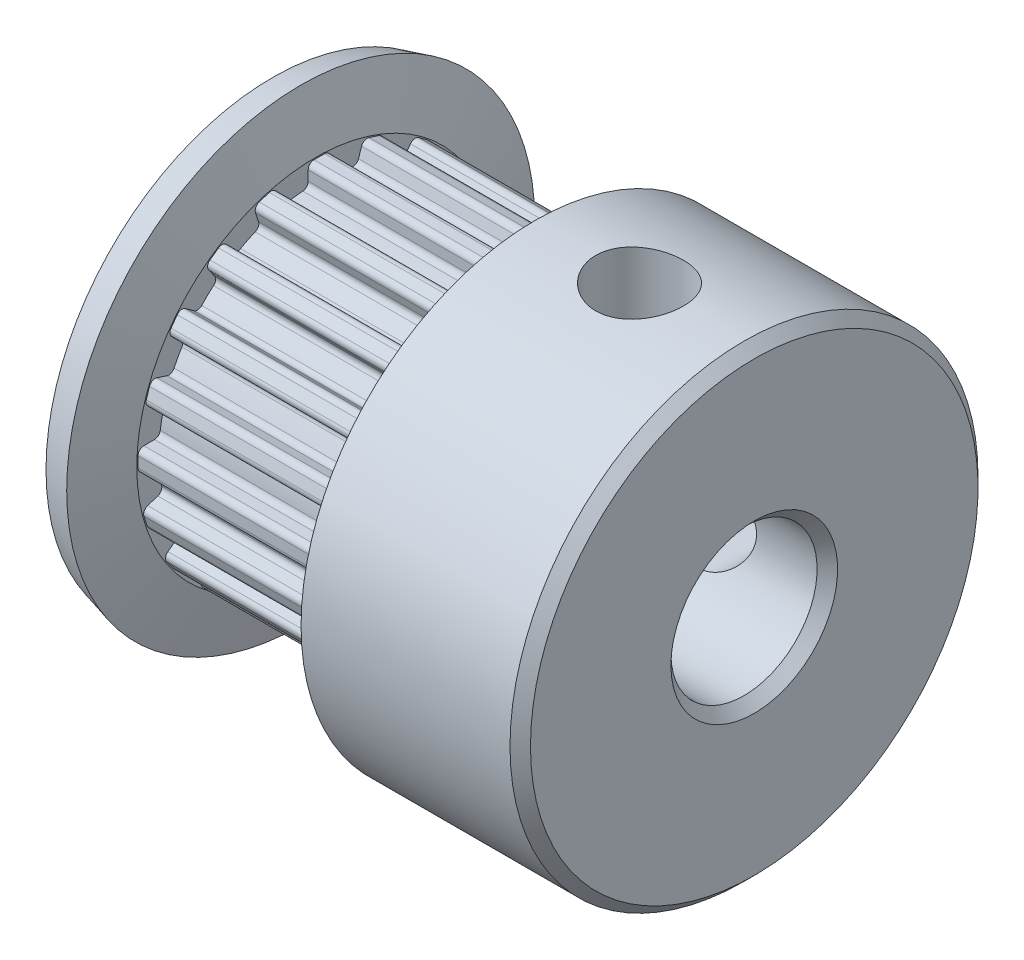
from build123d import *

# Parameters (mm, degrees)
SKETCH2_W                = 0.76
SKETCH2_H                = 0.76
BOSS_EXTRUDE1_DEPTH      = 7
FILLET1_R                = 0.2
CIRPATTERN2_COUNT        = 20
FILLET1_OF_CIRPATTERN2_R = 0.2
CUT_EXTRUDE2_START       = -3
SKETCH3_R                = 1.5
CUT_EXTRUDE2_DEPTH       = 12
CIRPATTERN3_COUNT        = 2
CIRPATTERN3_ANGLE        = 90


with BuildPart() as part:
    # Sketch1 → Revolve2 (revolve)
    with BuildSketch(Plane.XY):
        Polygon((8.222365613, 5.5), (1.078789587, 5.5), (0.572365613, 3.61), (0.572365613, 2.85), (-6.427634387, 2.85), (-6.427634387, 3.61), (-6.934058361, 5.5), (-7.899984187, 5.241180955), (-7.427634387, 3.478347502), (-7.427634387, 2.85), (-7.427634387, 0.35), (-7.077634387, 0), (8.222365613, 0), (8.572365613, 0.35), (8.572365613, 5.15), align=None)
    revolve(axis=Axis((-7.427634387, -2.5, 0), (1, 0, 0)))

    # Sketch2 → Boss-Extrude1 (add)
    with BuildSketch(Plane.ZY.offset(-0.572365613)):
        with Locations((-0.13, 3.186628075)):
            Rectangle(SKETCH2_W, SKETCH2_H)
    boss_extrude1 = extrude(amount=BOSS_EXTRUDE1_DEPTH)

    # Fillet1
    fillet1_edges = [part.edges().sort_by_distance(p)[0] for p in [
        (-2.927634387, 2.825636112, -0.51),
        (-2.927634387, 3.566628075, -0.51),
        (-2.927634387, 2.844155686, 0.25),
        (-2.927634387, 3.566628075, 0.25),
    ]]
    fillet(fillet1_edges, radius=FILLET1_R)

    # CirPattern2: Boss-Extrude1 ×20 about axis
    cirpattern2_axis = Axis((0, -2.5, 0), (1, 0, 0))
    for i in range(1, CIRPATTERN2_COUNT):
        add(boss_extrude1.rotate(cirpattern2_axis, i * 360 / CIRPATTERN2_COUNT))

    # Fillet1 of CirPattern2
    fillet1_of_cirpattern2_edges = [part.edges().sort_by_distance(p)[0] for p in [
        (-2.927634387, 2.722579595, 1.160673241),
        (-2.927634387, 3.42730483, 1.38965235),
        (-2.927634387, 2.505339841, 1.889199057),
        (-2.927634387, 3.192451914, 2.112455303),
        (-2.927634387, 2.108300599, 2.717731699),
        (-2.927634387, 2.70777569, 3.153275847),
        (-2.927634387, 1.676566458, 3.343470147),
        (-2.927634387, 2.261058898, 3.768128762),
        (-2.927634387, 1.042929033, 4.008759642),
        (-2.927634387, 1.478473181, 4.608234733),
        (-2.927634387, 0.43896165, 4.470459084),
        (-2.927634387, 0.863620265, 5.054951524),
        (-2.927634387, -0.369249112, 4.907382261),
        (-2.927634387, -0.140270003, 5.612107496),
        (-2.927634387, -1.086329201, 5.159848338),
        (-2.927634387, -0.863072955, 5.846960411),
        (-2.927634387, -1.99, 5.325636112),
        (-2.927634387, -1.99, 6.066628075),
        (-2.927634387, -2.75, 5.344155686),
        (-2.927634387, -2.75, 6.066628075),
        (-2.927634387, -3.660673241, 5.222579595),
        (-2.927634387, -3.88965235, 5.92730483),
        (-2.927634387, -4.389199057, 5.005339841),
        (-2.927634387, -4.612455303, 5.692451914),
        (-2.927634387, -5.217731699, 4.608300599),
        (-2.927634387, -5.653275847, 5.20777569),
        (-2.927634387, -5.843470147, 4.176566458),
        (-2.927634387, -6.268128762, 4.761058898),
        (-2.927634387, -6.508759642, 3.542929033),
        (-2.927634387, -7.108234733, 3.978473181),
        (-2.927634387, -6.970459084, 2.93896165),
        (-2.927634387, -7.554951524, 3.363620265),
        (-2.927634387, -7.407382261, 2.130750888),
        (-2.927634387, -8.112107496, 2.359729997),
        (-2.927634387, -7.659848338, 1.413670799),
        (-2.927634387, -8.346960411, 1.636927045),
        (-2.927634387, -7.825636112, 0.51),
        (-2.927634387, -8.566628075, 0.51),
        (-2.927634387, -7.844155686, -0.25),
        (-2.927634387, -8.566628075, -0.25),
        (-2.927634387, -7.722579595, -1.160673241),
        (-2.927634387, -8.42730483, -1.38965235),
        (-2.927634387, -7.505339841, -1.889199057),
        (-2.927634387, -8.192451914, -2.112455303),
        (-2.927634387, -7.108300599, -2.717731699),
        (-2.927634387, -7.70777569, -3.153275847),
        (-2.927634387, -6.676566458, -3.343470147),
        (-2.927634387, -7.261058898, -3.768128762),
        (-2.927634387, -6.042929033, -4.008759642),
        (-2.927634387, -6.478473181, -4.608234733),
        (-2.927634387, -5.43896165, -4.470459084),
        (-2.927634387, -5.863620265, -5.054951524),
        (-2.927634387, -4.630750888, -4.907382261),
        (-2.927634387, -4.859729997, -5.612107496),
        (-2.927634387, -3.913670799, -5.159848338),
        (-2.927634387, -4.136927045, -5.846960411),
        (-2.927634387, -3.01, -5.325636112),
        (-2.927634387, -3.01, -6.066628075),
        (-2.927634387, -2.25, -5.344155686),
        (-2.927634387, -2.25, -6.066628075),
        (-2.927634387, -1.339326759, -5.222579595),
        (-2.927634387, -1.11034765, -5.92730483),
        (-2.927634387, -0.610800943, -5.005339841),
        (-2.927634387, -0.387544697, -5.692451914),
        (-2.927634387, 0.217731699, -4.608300599),
        (-2.927634387, 0.653275847, -5.20777569),
        (-2.927634387, 0.843470147, -4.176566458),
        (-2.927634387, 1.268128762, -4.761058898),
        (-2.927634387, 1.508759642, -3.542929033),
        (-2.927634387, 2.108234733, -3.978473181),
        (-2.927634387, 1.970459084, -2.93896165),
        (-2.927634387, 2.554951524, -3.363620265),
        (-2.927634387, 2.407382261, -2.130750888),
        (-2.927634387, 3.112107496, -2.359729997),
        (-2.927634387, 2.659848338, -1.413670799),
        (-2.927634387, 3.346960411, -1.636927045),
    ]]
    fillet(fillet1_of_cirpattern2_edges, radius=FILLET1_OF_CIRPATTERN2_R)

    # Sketch3 → Cut-Extrude2 (cut)
    with BuildSketch(Plane(origin=(0, 0, 0), x_dir=(1, 0, 0), z_dir=(0, 1, 0)).offset(CUT_EXTRUDE2_START)):
        with Locations((4.6505776, 0)):
            Circle(SKETCH3_R)
    cut_extrude2 = extrude(amount=CUT_EXTRUDE2_DEPTH, mode=Mode.SUBTRACT)

    # CirPattern3: Cut-Extrude2 ×2 about axis
    cirpattern3_axis = Axis((-7.427634387, -2.5, 0), (-1, 0, 0))
    for i in range(1, CIRPATTERN3_COUNT):
        add(cut_extrude2.rotate(cirpattern3_axis, i * CIRPATTERN3_ANGLE / (CIRPATTERN3_COUNT - 1)), mode=Mode.SUBTRACT)


solid = part.part
